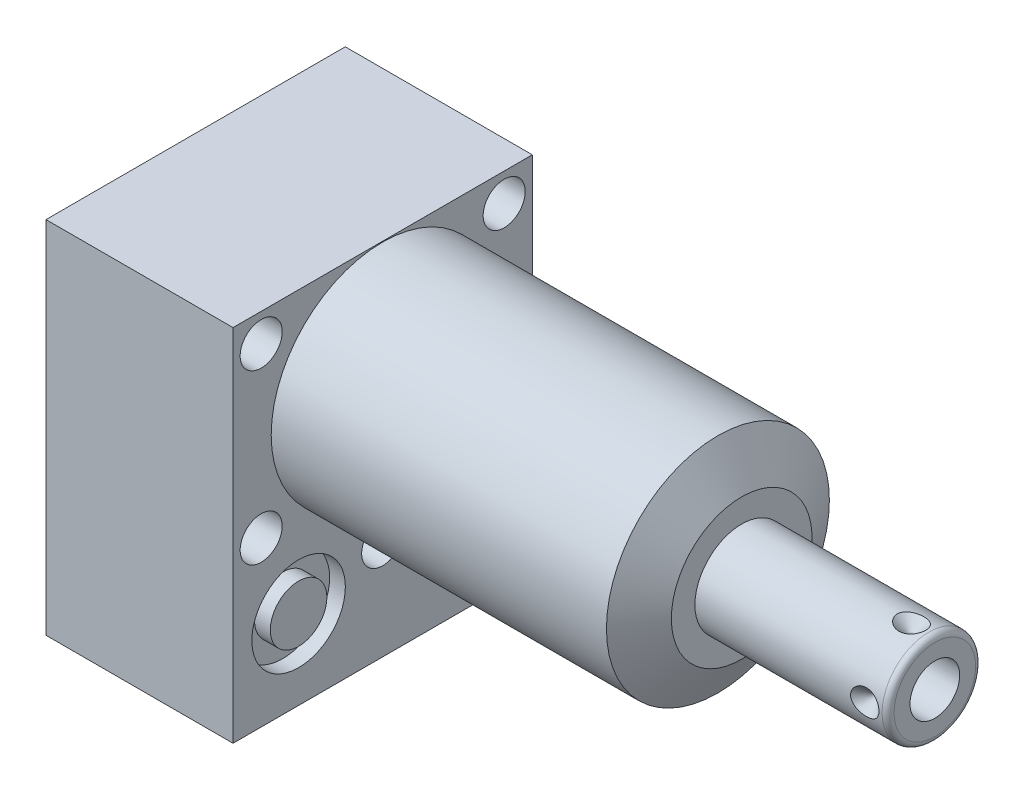
from build123d import *

# Parameters (mm, degrees)
SKETCH1_W           = 50.8
SKETCH1_H           = 61.1124
EXTRUDE1_DEPTH      = 60.9346
EXTRUDE1_DEPTH_BACK = 31.75
CUT_EXTRUDE1_REACH  = 62.935
SKETCH2_W           = 50.8
SKETCH2_H           = 61.1124
SKETCH2_R           = 18.923
SKETCH18_R          = 7.9375
CUT_EXTRUDE2_DEPTH  = 2.667
SKETCH19_R          = 7.9375
CUT_EXTRUDE3_DEPTH  = 2.667
SKETCH20_R          = 9.525
CUT_EXTRUDE4_DEPTH  = 0.254
SKETCH12_R          = 6.4389
EXTRUDE2_DEPTH      = 1.651
EXTRUDE3_START      = -2.667
SKETCH13_R          = 4.8006
EXTRUDE3_DEPTH      = 2.667
SKETCH14_R          = 1.7653
SKETCH15_R          = 1.7653
SKETCH21_W          = 3.5687
SKETCH21_H          = 31.75
HOLE1_AT_2_COUNT    = 2
HOLE1_AT_2_PITCH    = 44.445239059
HOLE1_AT_3_COUNT    = 2
HOLE1_AT_3_PITCH    = 28.5496
HOLE1_AT_4_COUNT    = 2
HOLE1_AT_4_PITCH    = 41.2496
HOLE1_AT_5_COUNT    = 2
HOLE1_AT_5_PITCH    = 50.165816652
SKETCH24_R          = 4.8006
EXTRUDE4_DEPTH      = 2.667
CIRPATTERN1_COUNT   = 4


with BuildPart() as part:
    # Sketch1 → Extrude1 (new body, two sides)
    with BuildSketch(Plane(origin=(0, 0, 0), x_dir=(0, 0, -1), z_dir=(1, 0, 0))) as extrude1_sk:
        with Locations((0, -11.5062)):
            Rectangle(SKETCH1_W, SKETCH1_H)
    extrude(amount=EXTRUDE1_DEPTH)
    extrude(extrude1_sk.sketch, amount=-EXTRUDE1_DEPTH_BACK)

    # Sketch2 → Cut-Extrude1 (cut, up to next)
    with BuildSketch(Plane(origin=(0, 0, 0), x_dir=(0, 0, -1), z_dir=(1, 0, 0)), mode=Mode.PRIVATE) as cut_extrude1_sk1:
        with Locations((0, -11.5062)):
            Rectangle(SKETCH2_W, SKETCH2_H)
        Circle(SKETCH2_R, mode=Mode.SUBTRACT)
    cut_extrude1_tool1 = extrude(cut_extrude1_sk1.sketch, amount=CUT_EXTRUDE1_REACH, mode=Mode.PRIVATE) & part.part
    add(cut_extrude1_tool1.solids().sort_by_distance((0, 18.970531, 0))[0], mode=Mode.SUBTRACT)

    # Sketch3 → Cut-Revolve1 (revolve, cut)
    with BuildSketch(Plane.XY, mode=Mode.PRIVATE) as cut_revolve1_sk:
        Polygon((56.90180837, 18.923), (60.9346, 11.938), (60.9346, 18.923), align=None)
    revolve(cut_revolve1_sk.sketch.rotate(Axis((56.700168788, 0, 0), (1, 0, 0)), 90), axis=Axis((56.700168788, 0, 0), (1, 0, 0)), mode=Mode.SUBTRACT)  # turned: the seam where the file's is

    # S2D0002 → Cut-Revolve2 (revolve, cut)
    with BuildSketch(Plane(origin=(-29.083, -28.575, 14.2748), x_dir=(0, 1, 0), z_dir=(0, 0, 1)), mode=Mode.PRIVATE) as cut_revolve2_sk:
        Polygon((0, 0), (4.5466, 0), (4.106586662, -2.0701), (3.4544, -2.722286662), (3.4544, -13.97), (0, -13.97), align=None)
    revolve(cut_revolve2_sk.sketch.rotate(Axis((-14.4145, -28.575, 14.2748), (-1, 0, 0)), 90), axis=Axis((-14.4145, -28.575, 14.2748), (-1, 0, 0)), mode=Mode.SUBTRACT)  # turned: the seam where the file's is

    # Sketch5 → Cut-Revolve3 (revolve, cut)
    with BuildSketch(Plane(origin=(-29.083, -28.575, -14.2748), x_dir=(0, 1, 0), z_dir=(0, 0, 1)), mode=Mode.PRIVATE) as cut_revolve3_sk:
        Polygon((0, 0), (4.5466, 0), (4.106586662, -2.0701), (3.4544, -2.722286662), (3.4544, -13.97), (0, -13.97), align=None)
    revolve(cut_revolve3_sk.sketch.rotate(Axis((-14.4145, -28.575, -14.2748), (-1, 0, 0)), 90), axis=Axis((-14.4145, -28.575, -14.2748), (-1, 0, 0)), mode=Mode.SUBTRACT)  # turned: the seam where the file's is

    # Sketch6 → Cut-Revolve4 (revolve, cut)
    with BuildSketch(Plane(origin=(-2.667, -28.575, 14.2748), x_dir=(0, -1, 0), z_dir=(0, 0, 1)), mode=Mode.PRIVATE) as cut_revolve4_sk:
        Polygon((0, 0), (4.5466, 0), (4.106586662, -2.0701), (3.4544, -2.722286662), (3.4544, -12.192), (0, -12.192), align=None)
    revolve(cut_revolve4_sk.sketch.rotate(Axis((-15.4686, -28.575, 14.2748), (1, 0, 0)), 90), axis=Axis((-15.4686, -28.575, 14.2748), (1, 0, 0)), mode=Mode.SUBTRACT)  # turned: the seam where the file's is

    # Sketch7 → Cut-Revolve5 (revolve, cut)
    with BuildSketch(Plane(origin=(-2.667, -28.575, -14.2748), x_dir=(0, -1, 0), z_dir=(0, 0, 1)), mode=Mode.PRIVATE) as cut_revolve5_sk:
        Polygon((0, 0), (4.5466, 0), (4.106586662, -2.0701), (3.4544, -2.722286662), (3.4544, -12.192), (0, -12.192), align=None)
    revolve(cut_revolve5_sk.sketch.rotate(Axis((-15.4686, -28.575, -14.2748), (1, 0, 0)), 90), axis=Axis((-15.4686, -28.575, -14.2748), (1, 0, 0)), mode=Mode.SUBTRACT)  # turned: the seam where the file's is

    # Sketch18 → Cut-Extrude2 (cut)
    with BuildSketch(Plane.ZY.offset(31.75)):
        with Locations((-14.2748, -28.575)):
            Circle(SKETCH18_R)
        with Locations((14.2748, -28.575)):
            Circle(SKETCH18_R)
    extrude(amount=-CUT_EXTRUDE2_DEPTH, mode=Mode.SUBTRACT)

    # Sketch19 → Cut-Extrude3 (cut)
    with BuildSketch(Plane(origin=(0, 0, 0), x_dir=(0, 0, -1), z_dir=(1, 0, 0))):
        with Locations((-14.2748, -28.575)):
            Circle(SKETCH19_R)
        with Locations((14.2748, -28.575)):
            Circle(SKETCH19_R)
    extrude(amount=-CUT_EXTRUDE3_DEPTH, mode=Mode.SUBTRACT)

    # Sketch8 → Cut-Revolve6 (revolve, cut)
    with BuildSketch(Plane(origin=(-15.875, -43.688, 14.2748), x_dir=(-1, 0, 0), z_dir=(0, 0, 1)), mode=Mode.PRIVATE) as cut_revolve6_sk:
        Polygon((0, -1.8796), (6.1849, -1.8796), (5.642306865, -4.4323), (4.9784, -5.096206865), (4.9784, -20.9296), (0, -20.9296), align=None)
    revolve(cut_revolve6_sk.sketch.rotate(Axis((-15.875, -17.018, 14.2748), (0, -1, 0)), 270), axis=Axis((-15.875, -17.018, 14.2748), (0, -1, 0)), mode=Mode.SUBTRACT)  # turned: the seam where the file's is

    # Sketch9 → Cut-Revolve7 (revolve, cut)
    with BuildSketch(Plane(origin=(-15.875, -43.688, -14.2748), x_dir=(-1, 0, 0), z_dir=(0, 0, 1)), mode=Mode.PRIVATE) as cut_revolve7_sk:
        Polygon((0, -1.8796), (6.1849, -1.8796), (5.642306865, -4.4323), (4.9784, -5.096206865), (4.9784, -20.9296), (0, -20.9296), align=None)
    revolve(cut_revolve7_sk.sketch.rotate(Axis((-15.875, -17.018, -14.2748), (0, -1, 0)), 270), axis=Axis((-15.875, -17.018, -14.2748), (0, -1, 0)), mode=Mode.SUBTRACT)  # turned: the seam where the file's is

    # Sketch20 → Cut-Extrude4 (cut)
    with BuildSketch(Plane.XZ.offset(42.0624)):
        with Locations(Location((-15.875, 14.2748, 0), (0, 0, 270))):  # turned: the seam where the file's is
            Circle(SKETCH20_R)
        with Locations(Location((-15.875, -14.2748, 0), (0, 0, 270))):  # turned: the seam where the file's is
            Circle(SKETCH20_R)
    extrude(amount=-CUT_EXTRUDE4_DEPTH, mode=Mode.SUBTRACT)

    # Sketch10 → Revolve1 (revolve)
    with BuildSketch(Plane.XY, mode=Mode.PRIVATE) as revolve1_sk:
        with BuildLine():
            Line((60.9346, 0), (60.9346, 7.9375))
            Line((60.9346, 7.9375), (92.71, 7.9375))
            ThreePointArc((92.71, 7.9375), (93.42842049, 7.63992049), (93.726, 6.9215))
            Line((93.726, 6.9215), (93.726, 0))
            Line((93.726, 0), (60.9346, 0))
        make_face()
    revolve(revolve1_sk.sketch.rotate(Axis((59.59348, 0, 0), (1, 0, 0)), 90), axis=Axis((59.59348, 0, 0), (1, 0, 0)))  # turned: the seam where the file's is

    # S2D0001 → Cut-Revolve8 (revolve, cut)
    with BuildSketch(Plane(origin=(87.757, -4.2164, 0), x_dir=(0, -1, 0), z_dir=(0, 0, 1)), mode=Mode.PRIVATE) as cut_revolve8_sk:
        Polygon((0, 5.969), (0, -9.271), (-4.2164, -11.804468714), (-4.2164, 5.969), align=None)
    revolve(cut_revolve8_sk.sketch.rotate(Axis((62.891960697, 0, 0), (1, 0, 0)), 270), axis=Axis((62.891960697, 0, 0), (1, 0, 0)), mode=Mode.SUBTRACT)  # turned: the seam where the file's is

    # Sketch12 → Extrude2 (add)
    with BuildSketch(Plane(origin=(-31.75, -41.8084, 0), x_dir=(0, 0, -1), z_dir=(0, -1, 0))):
        with Locations((-14.2748, 15.875)):
            Circle(SKETCH12_R)
    extrude(amount=EXTRUDE2_DEPTH)

    # Sketch13 → Extrude3 (add)
    with BuildSketch(Plane(origin=(0, 0, 0), x_dir=(0, 0, -1), z_dir=(1, 0, 0)).offset(EXTRUDE3_START)):
        with Locations((-14.2748, -28.575)):
            Circle(SKETCH13_R)
    extrude(amount=EXTRUDE3_DEPTH)

    # Sketch16 → Cut-Revolve9 (revolve, cut)
    with BuildSketch(Plane(origin=(83.7946, 7.9375, 0), x_dir=(-1, 0, 0), z_dir=(0, 0, -1)), mode=Mode.PRIVATE) as cut_revolve9_sk:
        Polygon((-5.969, 0), (-3.556, 0), (-5.969, -2.413), align=None)
    cut_revolve9 = revolve(cut_revolve9_sk.sketch.rotate(Axis((89.7636, 4.132061843, 0), (0, 1, 0)), 90), axis=Axis((89.7636, 4.132061843, 0), (0, 1, 0)), mode=Mode.SUBTRACT)  # turned: the seam where the file's is

    # Sketch21 → Hole1 (revolve, cut)
    with BuildSketch(Plane(origin=(0, 14.2748, 20.6248), x_dir=(0, 0, -1), z_dir=(0, 1, 0))):
        with Locations((1.78435, 15.875)):
            Rectangle(SKETCH21_W, SKETCH21_H)
    hole1 = revolve(axis=Axis((-110, 14.2748, 20.6248), (1, 0, 0)), mode=Mode.SUBTRACT)

    # Hole1 at 2: Hole1 ×2
    with Locations(*[Vector(0, -0.885809163, -0.464049703) * (i * HOLE1_AT_2_PITCH) for i in range(1, HOLE1_AT_2_COUNT)]):
        add(hole1, mode=Mode.SUBTRACT)

    # Hole1 at 3: Hole1 ×2
    with Locations(*[(0, -i * HOLE1_AT_3_PITCH, 0) for i in range(1, HOLE1_AT_3_COUNT)]):
        add(hole1, mode=Mode.SUBTRACT)

    # Hole1 at 4: Hole1 ×2
    with Locations(*[(0, 0, -i * HOLE1_AT_4_PITCH) for i in range(1, HOLE1_AT_4_COUNT)]):
        add(hole1, mode=Mode.SUBTRACT)

    # Hole1 at 5: Hole1 ×2
    with Locations(*[Vector(0, -0.569104659, -0.822265095) * (i * HOLE1_AT_5_PITCH) for i in range(1, HOLE1_AT_5_COUNT)]):
        add(hole1, mode=Mode.SUBTRACT)

    # Sketch24 → Extrude4 (add)
    with BuildSketch(Plane.ZY.offset(29.083)):
        with Locations(Location((14.2748, -28.575, 0), (0, 0, 180))):  # turned: the seam where the file's is
            Circle(SKETCH24_R)
    extrude(amount=EXTRUDE4_DEPTH)

    # CirPattern1: Cut-Revolve9 ×4 about axis
    cirpattern1_axis = Axis((59.59348, 0, 0), (-1, 0, 0))
    for i in range(1, CIRPATTERN1_COUNT):
        add(cut_revolve9.rotate(cirpattern1_axis, i * 360 / CIRPATTERN1_COUNT), mode=Mode.SUBTRACT)


with BuildPart() as body_2:
    # Sketch14 → Revolve2 (revolve)
    with BuildSketch(Plane(origin=(0, -28.575, -14.2748), x_dir=(0, 0, -1), z_dir=(0, -1, 0)), mode=Mode.PRIVATE) as revolve2_sk:
        with Locations((6.1722, -0.9017)):
            Circle(SKETCH14_R)
    revolve(revolve2_sk.sketch.rotate(Axis((-2.84353, -28.575, -14.2748), (1, 0, 0)), 180), axis=Axis((-2.84353, -28.575, -14.2748), (1, 0, 0)))  # turned: the seam where the file's is


with BuildPart() as body_3:
    # Sketch15 → Revolve3 (revolve)
    with BuildSketch(Plane(origin=(0, -28.575, -14.2748), x_dir=(0, 0, -1), z_dir=(0, -1, 0)), mode=Mode.PRIVATE) as revolve3_sk:
        with Locations((6.1722, -30.8483)):
            Circle(SKETCH15_R)
    revolve(revolve3_sk.sketch.rotate(Axis((-32.79013, -28.575, -14.2748), (1, 0, 0)), 180), axis=Axis((-32.79013, -28.575, -14.2748), (1, 0, 0)))  # turned: the seam where the file's is


solid = Compound([part.part, body_2.part, body_3.part])
